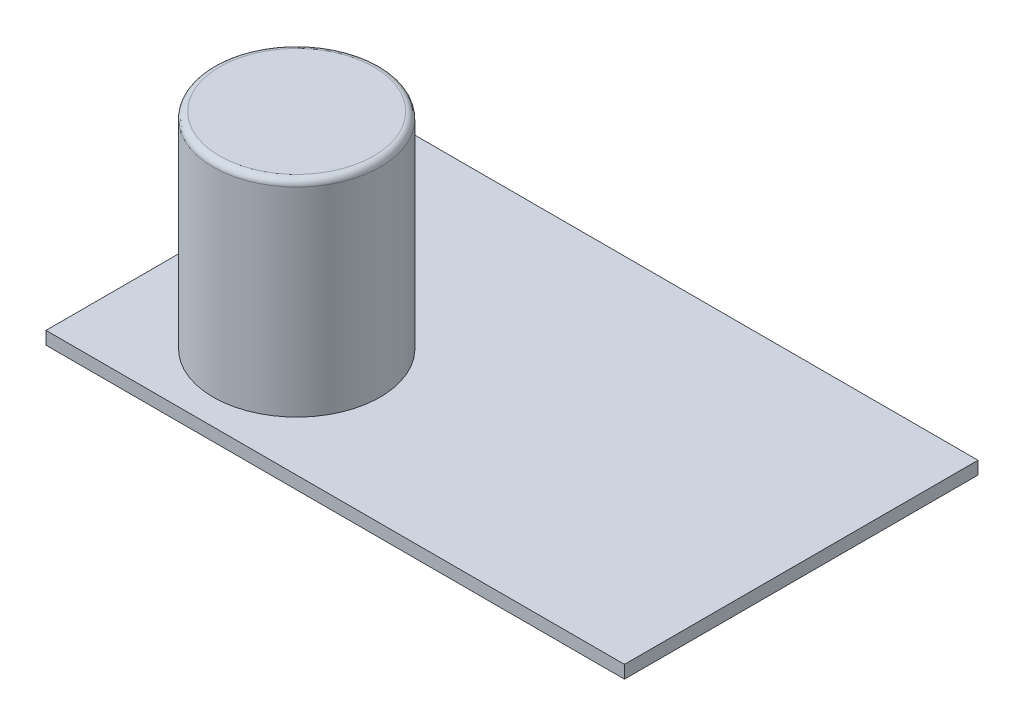
from build123d import *

# Parameters (mm, degrees)
SKETCH_1_W      = 45
SKETCH_1_H      = 27.5
EXTRUDE_1_DEPTH = 1
SKETCH_2_R      = 6.5
EXTRUDE_2_DEPTH = 16
FILLET_1_R      = 0.5


with BuildPart() as part:
    # Эскиз1 → Бобышка-Вытянуть1 (new body)
    with BuildSketch(Plane(origin=(0, 0, 0), x_dir=(1, 0, 0), z_dir=(0, 1, 0))):
        with Locations((22.5, 13.75)):
            Rectangle(SKETCH_1_W, SKETCH_1_H)
    extrude(amount=EXTRUDE_1_DEPTH)


with BuildPart() as body_2:
    # Эскиз2 → Бобышка-Вытянуть2 (new body)
    with BuildSketch(Plane(origin=(0, 1, 0), x_dir=(1, 0, 0), z_dir=(0, 1, 0))):
        with Locations((11, 8.5)):
            Circle(SKETCH_2_R)
    extrude(amount=EXTRUDE_2_DEPTH)

    # Скругление1
    fillet_1_edges = [body_2.edges().sort_by_distance(p)[0] for p in [
        (4.5, 17, -8.5),
    ]]
    fillet(fillet_1_edges, radius=FILLET_1_R)


solid = Compound([part.part, body_2.part])
